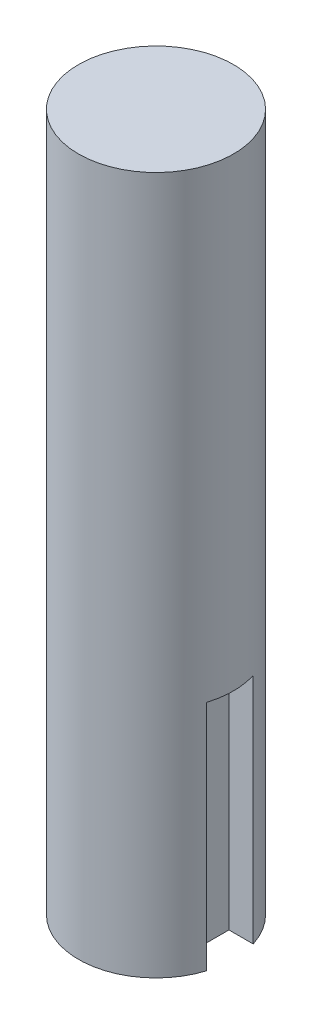
from build123d import *

# Parameters (mm, degrees)
SKETCH1_R           = 10
BOSS_EXTRUDE1_DEPTH = 90
CUT_EXTRUDE1_DEPTH  = 30


with BuildPart() as part:
    # Sketch1 → Boss-Extrude1 (new body)
    with BuildSketch(Plane(origin=(0, 0, 0), x_dir=(1, 0, 0), z_dir=(0, 1, 0))):
        Circle(SKETCH1_R)
    extrude(amount=BOSS_EXTRUDE1_DEPTH)

    # Sketch1_3 → Cut-Extrude1 (cut)
    with BuildSketch(Plane(origin=(0, 0, 0), x_dir=(1, 0, 0), z_dir=(0, 1, 0))):
        with BuildLine():
            Line((9.539392014, 3), (6.409392014, 3))
            Line((6.409392014, 3), (6.409392014, -3))
            Line((6.409392014, -3), (9.539392014, -3))
            ThreePointArc((9.539392014, -3), (9.884177258, -1.517576993), (10, 0))
            ThreePointArc((10, 0), (9.884177258, 1.517576993), (9.539392014, 3))
        make_face()
    extrude(amount=CUT_EXTRUDE1_DEPTH, mode=Mode.SUBTRACT)


solid = part.part
